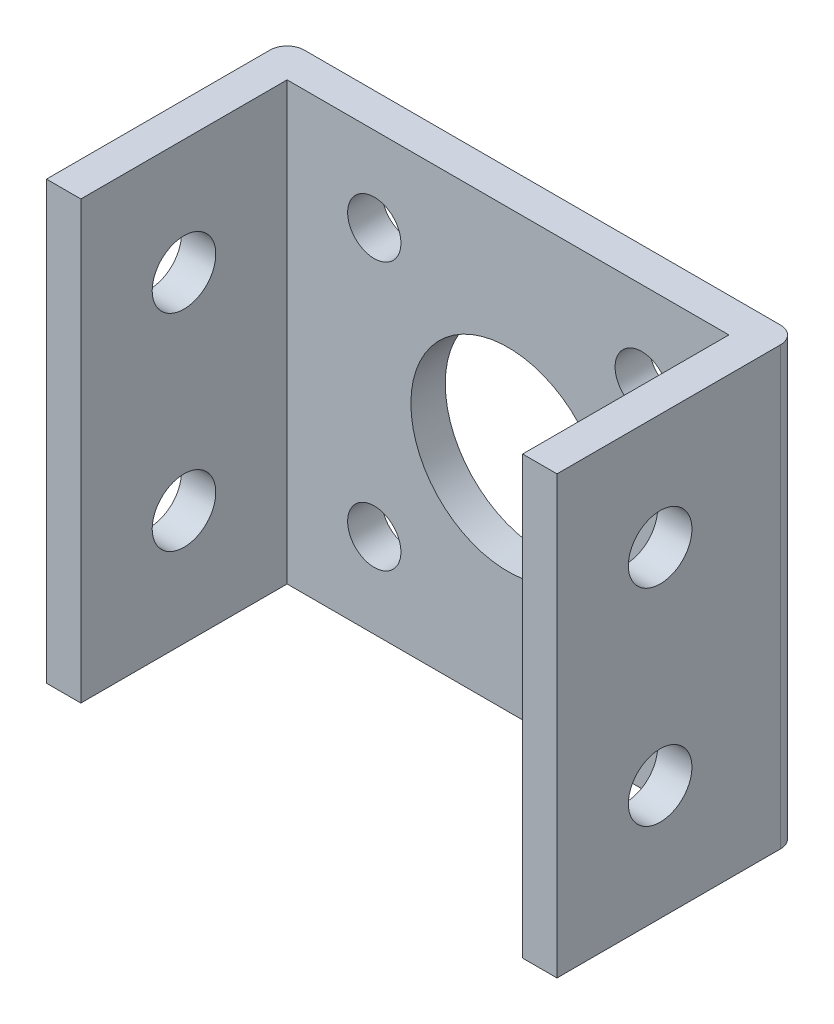
from build123d import *

# Parameters (mm, degrees)
BOSS_EXTRUDE1_DEPTH = 12.7
SKETCH2_R           = 1.85
CUT_EXTRUDE1_DEPTH  = 30.7
SKETCH3_R           = 5.65
CUT_EXTRUDE2_DEPTH  = 15
SKETCH4_R           = 1.55
CUT_EXTRUDE3_DEPTH  = 3
FILLET1_R           = 1


with BuildPart() as part:
    # Sketch1 → Boss-Extrude1 (new body, symmetric)
    with BuildSketch(Plane(origin=(0, 0, 0), x_dir=(1, 0, 0), z_dir=(0, 1, 0))):
        Polygon((-14.85, 0), (14.85, 0), (14.85, -14), (12.85, -14), (12.85, -2), (-12.85, -2), (-12.85, -14), (-14.85, -14), align=None)
    extrude(amount=BOSS_EXTRUDE1_DEPTH, both=True)

    # Sketch2 → Cut-Extrude1 (cut, through all)
    with BuildSketch(Plane.ZY.offset(14.85)):
        with Locations((8, -6)):
            Circle(SKETCH2_R)
        with Locations((8, 6)):
            Circle(SKETCH2_R)
    extrude(amount=-CUT_EXTRUDE1_DEPTH, mode=Mode.SUBTRACT)

    # Sketch3 → Cut-Extrude2 (cut, through all)
    with BuildSketch(Plane(origin=(0, 0, 0), x_dir=(-1, 0, 0), z_dir=(0, 0, -1))):
        Circle(SKETCH3_R)
    extrude(amount=-CUT_EXTRUDE2_DEPTH, mode=Mode.SUBTRACT)

    # Sketch4 → Cut-Extrude3 (cut, through all)
    with BuildSketch(Plane.XY.offset(2)):
        with Locations((-7.78, 7.78)):
            Circle(SKETCH4_R)
        with Locations((-7.78, -7.78)):
            Circle(SKETCH4_R)
        with Locations((7.78, -7.78)):
            Circle(SKETCH4_R)
        with Locations((7.78, 7.78)):
            Circle(SKETCH4_R)
    extrude(amount=-CUT_EXTRUDE3_DEPTH, mode=Mode.SUBTRACT)

    # Fillet1
    fillet1_edges = [part.edges().sort_by_distance(p)[0] for p in [
        (-14.85, 0, 0),
        (14.85, 0, 0),
    ]]
    fillet(fillet1_edges, radius=FILLET1_R)


solid = part.part
